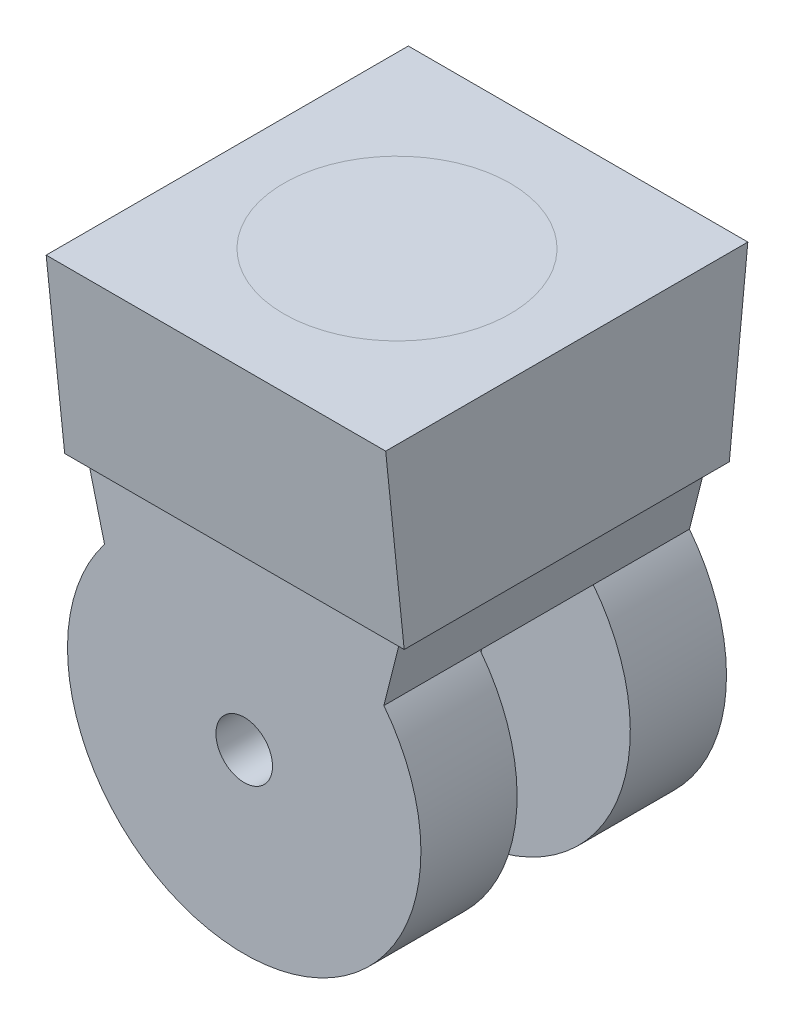
from build123d import *

# Parameters (mm, degrees)
SALIENTE_EXTRUIR1_DEPTH = 38.1
SALIENTE_EXTRUIR2_DEPTH = 34.29
CROQUIS3_R              = 39.658757808
CORTAR_EXTRUIR1_DEPTH   = 12.7
CROQUIS4_R              = 6.35
CORTAR_EXTRUIR2_DEPTH   = 75.93


with BuildPart() as part:
    # Croquis1 → Saliente-Extruir1 (new body, symmetric)
    with BuildSketch(Plane(origin=(0, 0, 0), x_dir=(0, 0, -1), z_dir=(1, 0, 0))):
        Polygon((-40.64, 20.319999995), (-36.486122257, -20.319999995), (0, -20.319999995), (36.486122257, -20.319999995), (40.64, 20.319999995), align=None)
    extrude(amount=SALIENTE_EXTRUIR1_DEPTH, both=True)

    # Croquis2 → Saliente-Extruir2 (add, symmetric)
    with BuildSketch(Plane.XY):
        with BuildLine():
            Line((35.223664747, -20.319999995), (31.348920302, -35.687560492))
            ThreePointArc((31.348920302, -35.687560492), (0, -99.63751561), (-31.348920302, -35.687560492))
            Line((-31.348920302, -35.687560492), (-35.223664747, -20.319999995))
            Line((-35.223664747, -20.319999995), (35.223664747, -20.319999995))
        make_face()
    extrude(amount=SALIENTE_EXTRUIR2_DEPTH, both=True)

    # Croquis3 → Cortar-Extruir1 (cut, symmetric)
    with BuildSketch(Plane.XY):
        with Locations((0, -59.978757803)):
            Circle(CROQUIS3_R)
    extrude(amount=CORTAR_EXTRUIR1_DEPTH, both=True, mode=Mode.SUBTRACT)

    # Croquis4 → Cortar-Extruir2 (cut, through all)
    with BuildSketch(Plane.XY.offset(34.29)):
        with Locations((0, -59.978757803)):
            Circle(CROQUIS4_R)
    extrude(amount=-CORTAR_EXTRUIR2_DEPTH, mode=Mode.SUBTRACT)


solid = part.part
